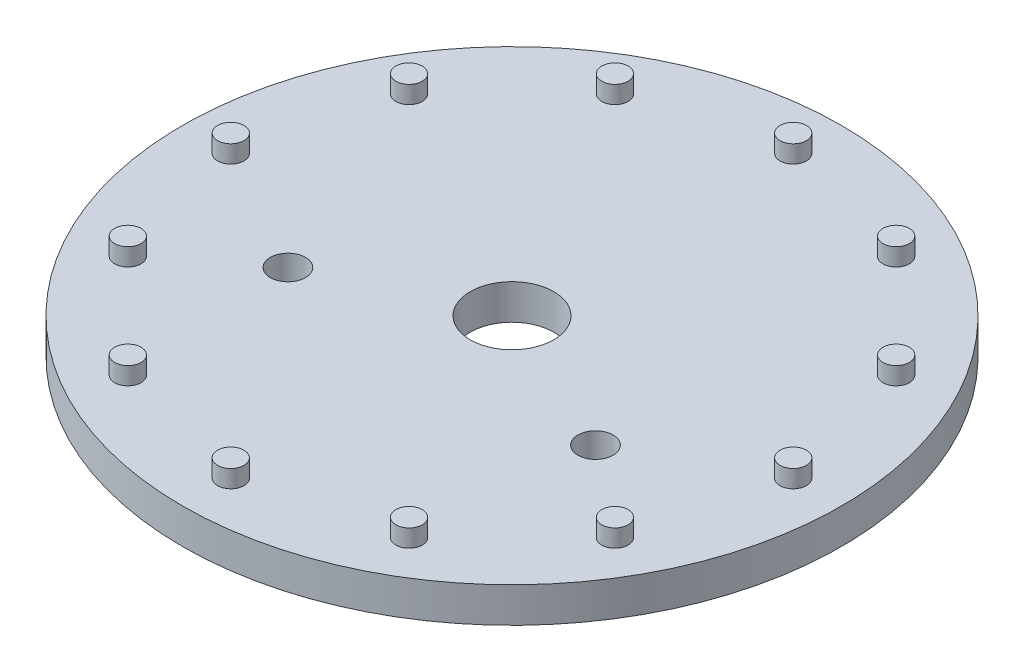
from build123d import *

# Parameters (mm, degrees)
SKETCH1_R           = 37.5
BOSS_EXTRUDE1_DEPTH = 4
SKETCH4_R           = 1.5
BOSS_EXTRUDE2_DEPTH = 2
SKETCH5_R           = 2
CUT_EXTRUDE2_DEPTH  = 10
SKETCH6_R           = 4.75
CUT_EXTRUDE3_DEPTH  = 42


with BuildPart() as part:
    # Sketch1 → Boss-Extrude1 (new body)
    with BuildSketch(Plane(origin=(0, 0, 0), x_dir=(1, 0, 0), z_dir=(0, 1, 0))):
        Circle(SKETCH1_R)
    extrude(amount=BOSS_EXTRUDE1_DEPTH)

    # Sketch4 → Boss-Extrude2 (add)
    with BuildSketch(Plane(origin=(0, 4, 0), x_dir=(1, 0, 0), z_dir=(0, 1, 0))):
        with Locations((0, 32)):
            Circle(SKETCH4_R)
        with Locations((16, 27.712812921)):
            Circle(SKETCH4_R)
        with Locations((27.712812921, 16)):
            Circle(SKETCH4_R)
        with Locations((32, 0)):
            Circle(SKETCH4_R)
        with Locations((27.712812921, -16)):
            Circle(SKETCH4_R)
        with Locations((16, -27.712812921)):
            Circle(SKETCH4_R)
        with Locations((0, -32)):
            Circle(SKETCH4_R)
        with Locations((-16, -27.712812921)):
            Circle(SKETCH4_R)
        with Locations((-27.712812921, -16)):
            Circle(SKETCH4_R)
        with Locations((-32, 0)):
            Circle(SKETCH4_R)
        with Locations((-27.712812921, 16)):
            Circle(SKETCH4_R)
        with Locations((-16, 27.712812921)):
            Circle(SKETCH4_R)
    extrude(amount=BOSS_EXTRUDE2_DEPTH)

    # Sketch5 → Cut-Extrude2 (cut)
    with BuildSketch(Plane(origin=(0, 4, 0), x_dir=(1, 0, 0), z_dir=(0, 1, 0))):
        with Locations((-17.5, -8)):
            Circle(SKETCH5_R)
        with Locations((17.5, -8)):
            Circle(SKETCH5_R)
    extrude(amount=-CUT_EXTRUDE2_DEPTH, mode=Mode.SUBTRACT)

    # Sketch6 → Cut-Extrude3 (cut)
    with BuildSketch(Plane(origin=(0, 4, 0), x_dir=(1, 0, 0), z_dir=(0, 1, 0))):
        Circle(SKETCH6_R)
    extrude(amount=-CUT_EXTRUDE3_DEPTH, mode=Mode.SUBTRACT)


solid = part.part
